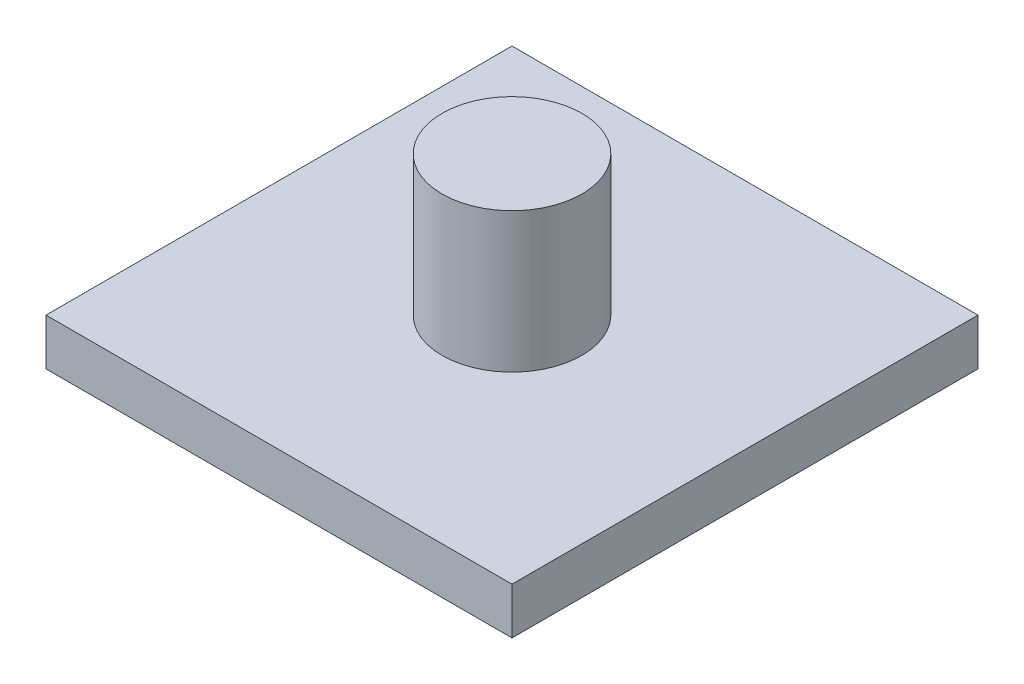
from build123d import *

# Parameters (mm, degrees)
SKETCH1_W           = 20
SKETCH1_H           = 20
BOSS_EXTRUDE1_DEPTH = 2
SKETCH2_R           = 3
BOSS_EXTRUDE2_DEPTH = 6


with BuildPart() as part:
    # Sketch1 → Boss-Extrude1 (new body)
    with BuildSketch(Plane(origin=(0, 0, 0), x_dir=(1, 0, 0), z_dir=(0, 1, 0))):
        with Locations((10, 10)):
            Rectangle(SKETCH1_W, SKETCH1_H)
    extrude(amount=BOSS_EXTRUDE1_DEPTH)

    # Sketch2 → Boss-Extrude2 (add)
    with BuildSketch(Plane(origin=(0, 2, 0), x_dir=(1, 0, 0), z_dir=(0, 1, 0))):
        with Locations((10, 10)):
            Circle(SKETCH2_R)
    extrude(amount=BOSS_EXTRUDE2_DEPTH)


solid = part.part
